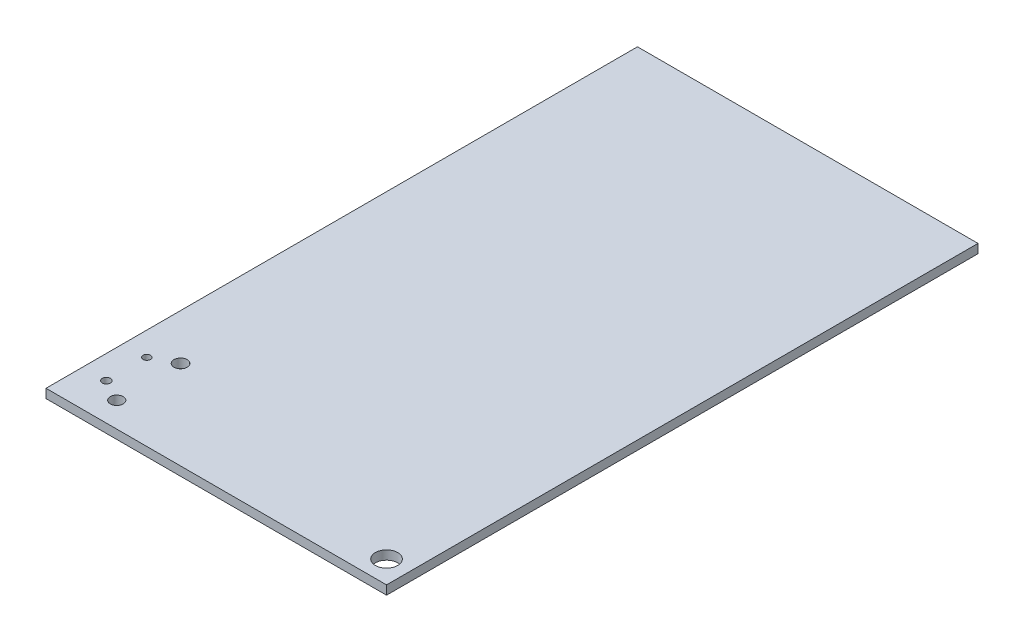
from build123d import *

# Parameters (mm, degrees)
SKETCH1_W           = 38
SKETCH1_H           = 66
BOSS_EXTRUDE1_DEPTH = 1
SKETCH2_R           = 1.25
CUT_EXTRUDE1_DEPTH  = 2
SKETCH3_R           = 0.456831937
SKETCH3_R_2         = 0.409961783
SKETCH3_R_3         = 0.739914173
SKETCH3_R_4         = 0.716276255
CUT_EXTRUDE2_DEPTH  = 2


with BuildPart() as part:
    # Sketch1 → Boss-Extrude1 (new body)
    with BuildSketch(Plane(origin=(0, 0, 0), x_dir=(1, 0, 0), z_dir=(0, 1, 0))):
        with Locations((19, 33)):
            Rectangle(SKETCH1_W, SKETCH1_H)
    extrude(amount=BOSS_EXTRUDE1_DEPTH)

    # Sketch2 → Cut-Extrude1 (cut, through all)
    with BuildSketch(Plane(origin=(0, 1, 0), x_dir=(1, 0, 0), z_dir=(0, 1, 0))):
        with Locations((35.5, 2.5)):
            Circle(SKETCH2_R)
    extrude(amount=-CUT_EXTRUDE1_DEPTH, mode=Mode.SUBTRACT)

    # Sketch3 → Cut-Extrude2 (cut, through all)
    with BuildSketch(Plane(origin=(0, 1, 0), x_dir=(1, 0, 0), z_dir=(0, 1, 0))):
        with Locations((2.638016887, 4.098772659)):
            Circle(SKETCH3_R)
        with Locations((2.638016887, 8.613282996)):
            Circle(SKETCH3_R_2)
        with Locations((5.107560434, 9.90998851)):
            Circle(SKETCH3_R_3)
        with Locations((5.107560434, 2.785166116)):
            Circle(SKETCH3_R_4)
    extrude(amount=-CUT_EXTRUDE2_DEPTH, mode=Mode.SUBTRACT)


solid = part.part
